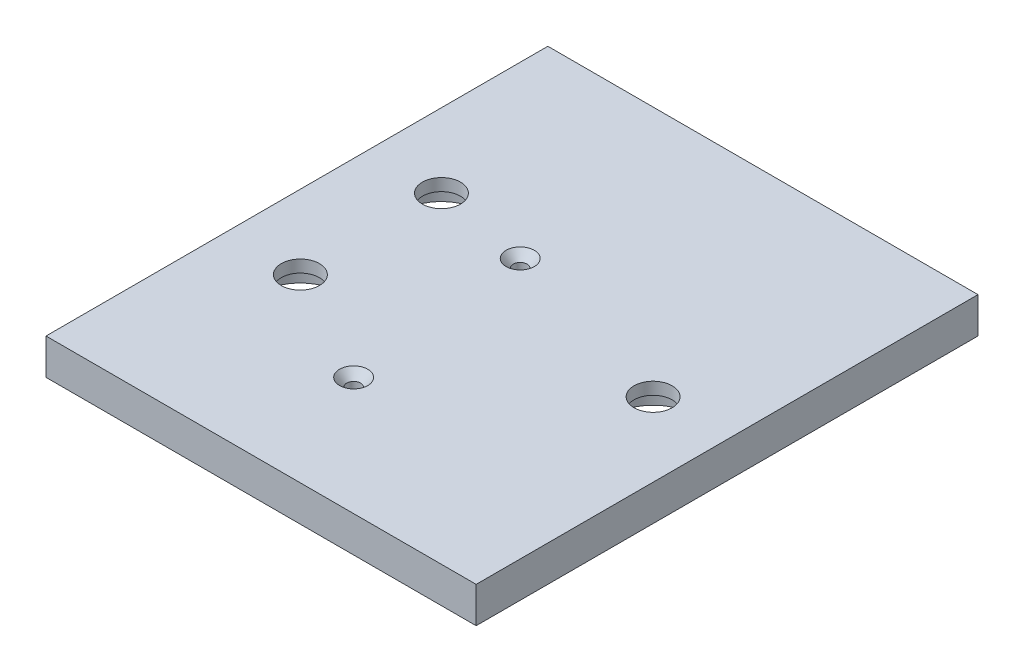
from build123d import *

# Parameters (mm, degrees)
SKETCH1_W                                            = 76.2
SKETCH1_H                                            = 88.9
BOSS_EXTRUDE1_DEPTH                                  = 6.35
CSK_FOR_2_FLAT_HEAD_SOCKET_CAP_SCREW1_D              = 2.4384
CSK_FOR_2_FLAT_HEAD_SOCKET_CAP_SCREW1_DEPTH          = 6.4
CSK_FOR_2_FLAT_HEAD_SOCKET_CAP_SCREW1_CSINK_D        = 5.0038
CSK_FOR_2_FLAT_HEAD_SOCKET_CAP_SCREW1_CSINK_ANGLE    = 82
CSK_FOR_2_FLAT_HEAD_SOCKET_CAP_SCREW1_TIP            = 0.732569267
CBORE_FOR_1_4_BINDING_HEAD_MACHINE_SCREW_D           = 6.7564
CBORE_FOR_1_4_BINDING_HEAD_MACHINE_SCREW_DEPTH       = 6.4
CBORE_FOR_1_4_BINDING_HEAD_MACHINE_SCREW_CBORE_D     = 14.2875
CBORE_FOR_1_4_BINDING_HEAD_MACHINE_SCREW_CBORE_DEPTH = 4.191
CBORE_FOR_1_4_BINDING_HEAD_MACHINE_SCREW_TIP         = 2.029827343


with BuildPart() as part:
    # Sketch1 → Boss-Extrude1 (new body)
    with BuildSketch(Plane(origin=(0, 0, 0), x_dir=(1, 0, 0), z_dir=(0, 1, 0))):
        with Locations((38.1, 44.45)):
            Rectangle(SKETCH1_W, SKETCH1_H)
    extrude(amount=BOSS_EXTRUDE1_DEPTH)

    # CSK for #2 Flat Head Socket Cap Screw1
    with Locations(Plane(origin=(0, 6.35, 0), x_dir=(1, 0, 0), z_dir=(0, 1, 0))):
        with Locations((33.6, 20.9), (30.1, 53.9)):
            CounterSinkHole(CSK_FOR_2_FLAT_HEAD_SOCKET_CAP_SCREW1_D / 2, CSK_FOR_2_FLAT_HEAD_SOCKET_CAP_SCREW1_CSINK_D / 2, depth=CSK_FOR_2_FLAT_HEAD_SOCKET_CAP_SCREW1_DEPTH, counter_sink_angle=CSK_FOR_2_FLAT_HEAD_SOCKET_CAP_SCREW1_CSINK_ANGLE)
            with Locations((0, 0, -(CSK_FOR_2_FLAT_HEAD_SOCKET_CAP_SCREW1_DEPTH + CSK_FOR_2_FLAT_HEAD_SOCKET_CAP_SCREW1_TIP / 2))):  # 118° drill point
                Cone(0, CSK_FOR_2_FLAT_HEAD_SOCKET_CAP_SCREW1_D / 2, CSK_FOR_2_FLAT_HEAD_SOCKET_CAP_SCREW1_TIP, mode=Mode.SUBTRACT)

    # CBORE for 1/4 Binding Head Machine Screw1
    with Locations(Plane(origin=(0, 0, 0), x_dir=(-1, 0, 0), z_dir=(0, -1, 0))):
        with Locations((-63.0936, 44.45), (-13.1064, 31.9532), (-13.1064, 56.9468)):
            CounterBoreHole(CBORE_FOR_1_4_BINDING_HEAD_MACHINE_SCREW_D / 2, CBORE_FOR_1_4_BINDING_HEAD_MACHINE_SCREW_CBORE_D / 2, CBORE_FOR_1_4_BINDING_HEAD_MACHINE_SCREW_CBORE_DEPTH, depth=CBORE_FOR_1_4_BINDING_HEAD_MACHINE_SCREW_DEPTH)
            with Locations((0, 0, -(CBORE_FOR_1_4_BINDING_HEAD_MACHINE_SCREW_DEPTH + CBORE_FOR_1_4_BINDING_HEAD_MACHINE_SCREW_TIP / 2))):  # 118° drill point
                Cone(0, CBORE_FOR_1_4_BINDING_HEAD_MACHINE_SCREW_D / 2, CBORE_FOR_1_4_BINDING_HEAD_MACHINE_SCREW_TIP, mode=Mode.SUBTRACT)


solid = part.part
